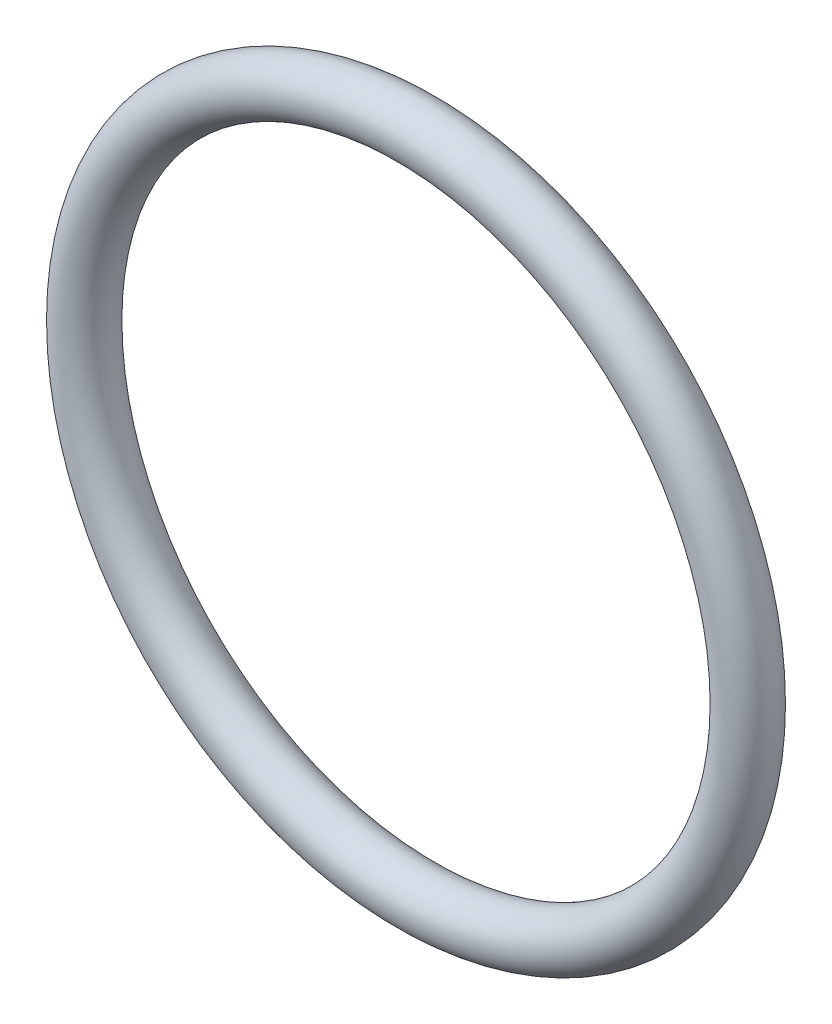
from build123d import *

# Parameters (mm, degrees)
SKETCH1_R = 0.889


with BuildPart() as part:
    # Sketch1 → Revolve1 (revolve)
    with BuildSketch(Plane(origin=(0, 0, 0), x_dir=(0, -1, 0), z_dir=(1, 0, 0))):
        with Locations((11.0617, 0)):
            Circle(SKETCH1_R)
    revolve(axis=Axis((0, 0, 0.889), (0, 0, -1)))


solid = part.part
